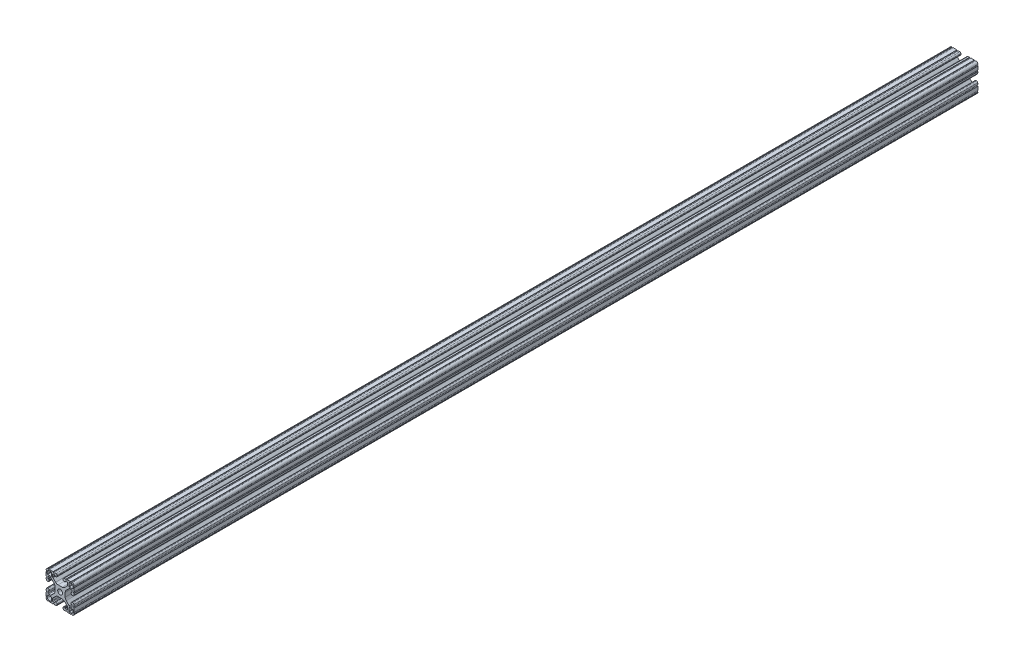
from build123d import *

# Parameters (mm, degrees)
BOSS_EXTRUDE1_DEPTH     = 609.6
CUT_EXTRUDE2_DEPTH      = 610.6
CUT_EXTRUDE2_DEPTH_BACK = 610.6
CUT_EXTRUDE1_DEPTH      = 610.6
CUT_EXTRUDE1_DEPTH_BACK = 610.6


with BuildPart() as part:
    # Sketch4 → Boss-Extrude1 (new body, symmetric)
    with BuildSketch(Plane.XY):
        with BuildLine():
            Line((15.764194098, -19.048065876), (5.596097049, -18.692988103))
            ThreePointArc((5.596097049, -18.692988103), (4.509548067, -18.209225328), (4.064, -17.106455165))
            Line((4.064, -17.106455165), (4.064, -16.343990692))
            ThreePointArc((4.064, -16.343990692), (4.548729837, -15.202038759), (5.706902951, -14.757457754))
            Line((5.706902951, -14.757457754), (6.490296708, -14.784814467))
            ThreePointArc((6.490296708, -14.784814467), (6.751068464, -14.900917533), (6.858, -15.165582372))
            Line((6.858, -15.165582372), (6.858, -15.689138401))
            ThreePointArc((6.858, -15.689138401), (6.964931536, -15.95380324), (7.225703292, -16.069906306))
            Line((7.225703292, -16.069906306), (9.465548524, -16.148123425))
            ThreePointArc((9.465548524, -16.148123425), (10.044635082, -15.925832923), (10.287, -15.354856956))
            Line((10.287, -15.354856956), (10.287, -12.771043484))
            ThreePointArc((10.287, -12.771043484), (10.226579379, -12.46728851), (10.054516008, -12.209777477))
            Line((10.054516008, -12.209777477), (6.093922742, -8.249184211))
            ThreePointArc((6.093922742, -8.249184211), (4.552976719, -7.219556996), (2.735306952, -6.858))
            Line((2.735306952, -6.858), (0, -6.858))
            Line((0, -6.858), (0, -3.2639))
            ThreePointArc((0, -3.2639), (2.307925823, -2.307925823), (3.2639, 0))
            Line((3.2639, 0), (6.858, 0))
            Line((6.858, 0), (6.858, -2.735306952))
            ThreePointArc((6.858, -2.735306952), (7.219556996, -4.552976719), (8.249184211, -6.093922742))
            Line((8.249184211, -6.093922742), (12.209777477, -10.054516008))
            ThreePointArc((12.209777477, -10.054516008), (12.46728851, -10.226579379), (12.771043484, -10.287))
            Line((12.771043484, -10.287), (15.354856956, -10.287))
            ThreePointArc((15.354856956, -10.287), (15.925832923, -10.044635082), (16.148123425, -9.465548524))
            Line((16.148123425, -9.465548524), (16.069906306, -7.225703292))
            ThreePointArc((16.069906306, -7.225703292), (15.95380324, -6.964931536), (15.689138401, -6.858))
            Line((15.689138401, -6.858), (15.165582372, -6.858))
            ThreePointArc((15.165582372, -6.858), (14.900917533, -6.751068464), (14.784814467, -6.490296708))
            Line((14.784814467, -6.490296708), (14.757457754, -5.706902951))
            ThreePointArc((14.757457754, -5.706902951), (15.202038759, -4.548729837), (16.343990692, -4.064))
            Line((16.343990692, -4.064), (17.106455165, -4.064))
            ThreePointArc((17.106455165, -4.064), (18.209225328, -4.509548067), (18.692988103, -5.596097049))
            Line((18.692988103, -5.596097049), (19.048065876, -15.764194098))
            ThreePointArc((19.048065876, -15.764194098), (18.12006403, -18.12006403), (15.764194098, -19.048065876))
        make_face()
        with BuildLine():
            Line((11.8872, -12.2682), (11.8872, -16.943575443))
            ThreePointArc((11.8872, -16.943575443), (11.994131536, -17.208240282), (12.254903292, -17.324343348))
            Line((12.254903292, -17.324343348), (14.445350862, -17.400835462))
            ThreePointArc((14.445350862, -17.400835462), (16.565633801, -16.565633801), (17.400835462, -14.445350862))
            Line((17.400835462, -14.445350862), (17.324343348, -12.254903292))
            ThreePointArc((17.324343348, -12.254903292), (17.208240282, -11.994131536), (16.943575443, -11.8872))
            Line((16.943575443, -11.8872), (12.2682, -11.8872))
            ThreePointArc((12.2682, -11.8872), (11.998792316, -11.998792316), (11.8872, -12.2682))
        make_face(mode=Mode.SUBTRACT)
    extrude(amount=BOSS_EXTRUDE1_DEPTH, both=True)

    # Sketch8 → Cut-Extrude2 (cut, two sides)
    with BuildSketch(Plane.XY) as cut_extrude2_sk:
        with BuildLine():
            Line((7.649186899, -18.76468358), (9.495813101, -18.829169188))
            Line((9.495813101, -18.829169188), (9.278946369, -18.421302187))
            ThreePointArc((9.278946369, -18.421302187), (8.600423087, -17.997313783), (7.893976718, -18.372937981))
            Line((7.893976718, -18.372937981), (7.649186899, -18.76468358))
        make_face()
        with BuildLine():
            Line((14.316686899, -18.997517811), (16.163313101, -19.062003418))
            Line((16.163313101, -19.062003418), (15.946446369, -18.654136417))
            ThreePointArc((15.946446369, -18.654136417), (15.267923087, -18.230148014), (14.561476718, -18.605772211))
            Line((14.561476718, -18.605772211), (14.316686899, -18.997517811))
        make_face()
        with BuildLine():
            Line((18.605772211, -14.561476718), (18.997517811, -14.316686899))
            Line((18.997517811, -14.316686899), (19.062003418, -16.163313101))
            Line((19.062003418, -16.163313101), (18.654136417, -15.946446369))
            ThreePointArc((18.654136417, -15.946446369), (18.230148014, -15.267923087), (18.605772211, -14.561476718))
        make_face()
        with BuildLine():
            Line((18.372937981, -7.893976718), (18.76468358, -7.649186899))
            Line((18.76468358, -7.649186899), (18.829169188, -9.495813101))
            Line((18.829169188, -9.495813101), (18.421302187, -9.278946369))
            ThreePointArc((18.421302187, -9.278946369), (17.997313783, -8.600423087), (18.372937981, -7.893976718))
        make_face()
    extrude(amount=CUT_EXTRUDE2_DEPTH, mode=Mode.SUBTRACT)
    extrude(cut_extrude2_sk.sketch, amount=-CUT_EXTRUDE2_DEPTH_BACK, mode=Mode.SUBTRACT)

    # Mirror1: part across plane


with BuildPart() as part_1:
    add(part.part)
    add(part.part.mirror(Plane(origin=(0, 0, 0), x_dir=(0, 0, 1), z_dir=(1, 0, 0))))

    # Mirror2: part across plane


with BuildPart() as part_2:
    add(part_1.part)
    add(part_1.part.mirror(Plane.ZX))

    # Sketch5 → Cut-Extrude1 (cut, two sides)
    with BuildSketch(Plane.XY) as cut_extrude1_sk:
        with BuildLine():
            Line((-10.133783723, 12.50797511), (-10.133783723, 11.99997511))
            ThreePointArc((-10.133783723, 11.99997511), (-10.084187138, 11.880238362), (-9.964450389, 11.830641777))
            Line((-9.964450389, 11.830641777), (-9.650582015, 11.830641777))
            Line((-9.650582015, 11.830641777), (-9.650582015, 12.50797511))
            Line((-9.650582015, 12.50797511), (-10.133783723, 12.50797511))
        make_face()
    extrude(amount=CUT_EXTRUDE1_DEPTH, mode=Mode.SUBTRACT)
    extrude(cut_extrude1_sk.sketch, amount=-CUT_EXTRUDE1_DEPTH_BACK, mode=Mode.SUBTRACT)


solid = part_2.part
